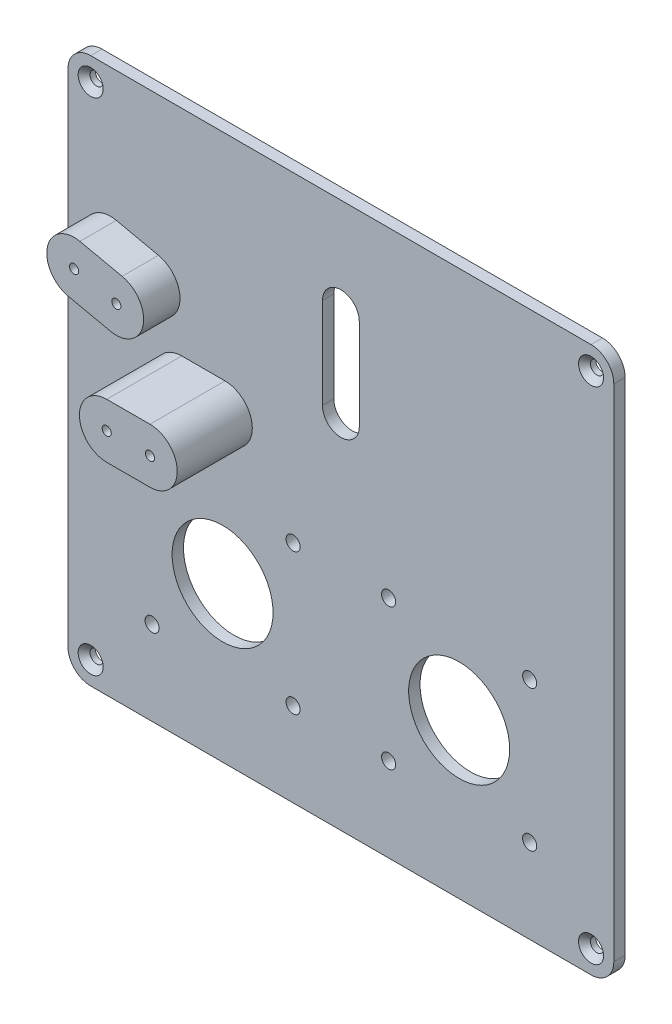
from build123d import *

# Parameters (mm, degrees)
SKETCH4_W                                      = 120
SKETCH4_H                                      = 120
BOSS_EXTRUDE2_DEPTH                            = 2.5
FILLET1_R                                      = 5
F_3_1_3_1_DIAMETER_HOLE1_D                     = 3.1
SKETCH8_R                                      = 11.1
CUT_EXTRUDE1_DEPTH                             = 10
SKETCH10_R                                     = 1
BOSS_EXTRUDE3_DEPTH                            = 16.499995
SKETCH11_R                                     = 1
BOSS_EXTRUDE4_DEPTH                            = 8
CSK_FOR_M2_5_FLAT_HEAD_MACHINE_SCREW2_AT_COUNT = 2
CSK_FOR_M2_5_FLAT_HEAD_MACHINE_SCREW2_AT_PITCH = 110
CSK_FOR_M2_5_FLAT_HEAD_MACHINE_SCREW_2_COUNT   = 2
CSK_FOR_M2_5_FLAT_HEAD_MACHINE_SCREW_2_PITCH   = 155.563491861
CSK_FOR_M2_5_FLAT_HEAD_MACHINE_SCREW_3_COUNT   = 2
CSK_FOR_M2_5_FLAT_HEAD_MACHINE_SCREW_3_PITCH   = 110


with BuildPart() as part:
    # Sketch4 → Boss-Extrude2 (new body)
    with BuildSketch(Plane.XY):
        with Locations((26, 26)):
            Rectangle(SKETCH4_W, SKETCH4_H)
        with BuildLine():
            Line((30.05, 64.884462408), (30.05, 44.884462408))
            ThreePointArc((30.05, 44.884462408), (26, 40.834462408), (21.95, 44.884462408))
            Line((21.95, 44.884462408), (21.95, 64.884462408))
            ThreePointArc((21.95, 64.884462408), (26, 68.934462408), (30.05, 64.884462408))
        make_face(mode=Mode.SUBTRACT)
    extrude(amount=BOSS_EXTRUDE2_DEPTH)

    # Fillet1
    fillet1_edges = [part.edges().sort_by_distance(p)[0] for p in [
        (-34, -34, 1.25),
        (-34, 86, 1.25),
        (86, 86, 1.25),
        (86, -34, 1.25),
    ]]
    fillet(fillet1_edges, radius=FILLET1_R)

    # Ø3.1 (3.1) Diameter Hole1 (through all)
    with Locations(Plane.XY.offset(2.5)):
        with Locations((-15.5, -15.5), (-15.5, 15.5), (15.5, 15.5), (15.5, -15.5), (36.5, -15.5), (36.5, 15.5), (67.5, -15.5), (67.5, 15.5)):
            Hole(F_3_1_3_1_DIAMETER_HOLE1_D / 2)

    # Sketch8 → Cut-Extrude1 (cut)
    with BuildSketch(Plane.XY.offset(2.5)):
        Circle(SKETCH8_R)
        with Locations((52, 0)):
            Circle(SKETCH8_R)
    extrude(amount=-CUT_EXTRUDE1_DEPTH, mode=Mode.SUBTRACT)

    # Sketch10 → Boss-Extrude3 (add)
    with BuildSketch(Plane.XY.offset(2.5)):
        with BuildLine():
            Line((-8.968535214, 38.85), (0.531464786, 38.85))
            ThreePointArc((0.531464786, 38.85), (6.531464786, 32.85), (0.531464786, 26.85))
            Line((0.531464786, 26.85), (-8.968535214, 26.85))
            ThreePointArc((-8.968535214, 26.85), (-14.968535214, 32.85), (-8.968535214, 38.85))
        make_face()
        with Locations((0.531464786, 32.85)):
            Circle(SKETCH10_R, mode=Mode.SUBTRACT)
        with Locations((-8.968535214, 32.85)):
            Circle(SKETCH10_R, mode=Mode.SUBTRACT)
    extrude(amount=BOSS_EXTRUDE3_DEPTH)

    # Sketch11 → Boss-Extrude4 (add)
    with BuildSketch(Plane.XY.offset(2.5)):
        with BuildLine():
            Line((-23.36906728, 57.461556068), (-14.085288007, 55.446254003))
            ThreePointArc((-14.085288007, 55.446254003), (-9.494670823, 48.309992105), (-16.63093272, 43.719374921))
            Line((-16.63093272, 43.719374921), (-25.914711993, 45.734676986))
            ThreePointArc((-25.914711993, 45.734676986), (-30.505329177, 52.870938884), (-23.36906728, 57.461556068))
        make_face()
        with Locations((-15.358110364, 49.582814462)):
            Circle(SKETCH11_R, mode=Mode.SUBTRACT)
        with Locations((-24.641889636, 51.598116527)):
            Circle(SKETCH11_R, mode=Mode.SUBTRACT)
    extrude(amount=BOSS_EXTRUDE4_DEPTH)

    # Sketch14 → CSK for M2.5 Flat Head Machine Screw2 (revolve, cut)
    with BuildSketch(Plane(origin=(81, 81, 2.5), x_dir=(0, -1, 0), z_dir=(1, 0, 0))):
        Polygon((0, 0), (0, 2.5), (1.45, 2.5), (1.45, 1.3), (2.75, 0), align=None)
    csk_for_m2_5_flat_head_machine_screw2 = revolve(axis=Axis((81, 81, 8.85), (0, 0, -1)), mode=Mode.SUBTRACT)

    # CSK for M2.5 Flat Head Machine Screw2 at: CSK for M2.5 Flat Head Machine Screw2 ×2
    with Locations(*[(0, -i * CSK_FOR_M2_5_FLAT_HEAD_MACHINE_SCREW2_AT_PITCH, 0) for i in range(1, CSK_FOR_M2_5_FLAT_HEAD_MACHINE_SCREW2_AT_COUNT)]):
        add(csk_for_m2_5_flat_head_machine_screw2, mode=Mode.SUBTRACT)

    # CSK for M2.5 Flat Head Machine Screw 2: CSK for M2.5 Flat Head Machine Screw2 ×2
    with Locations(*[Vector(-0.707106781, -0.707106781, 0) * (i * CSK_FOR_M2_5_FLAT_HEAD_MACHINE_SCREW_2_PITCH) for i in range(1, CSK_FOR_M2_5_FLAT_HEAD_MACHINE_SCREW_2_COUNT)]):
        add(csk_for_m2_5_flat_head_machine_screw2, mode=Mode.SUBTRACT)

    # CSK for M2.5 Flat Head Machine Screw 3: CSK for M2.5 Flat Head Machine Screw2 ×2
    with Locations(*[(-i * CSK_FOR_M2_5_FLAT_HEAD_MACHINE_SCREW_3_PITCH, 0, 0) for i in range(1, CSK_FOR_M2_5_FLAT_HEAD_MACHINE_SCREW_3_COUNT)]):
        add(csk_for_m2_5_flat_head_machine_screw2, mode=Mode.SUBTRACT)


solid = part.part
